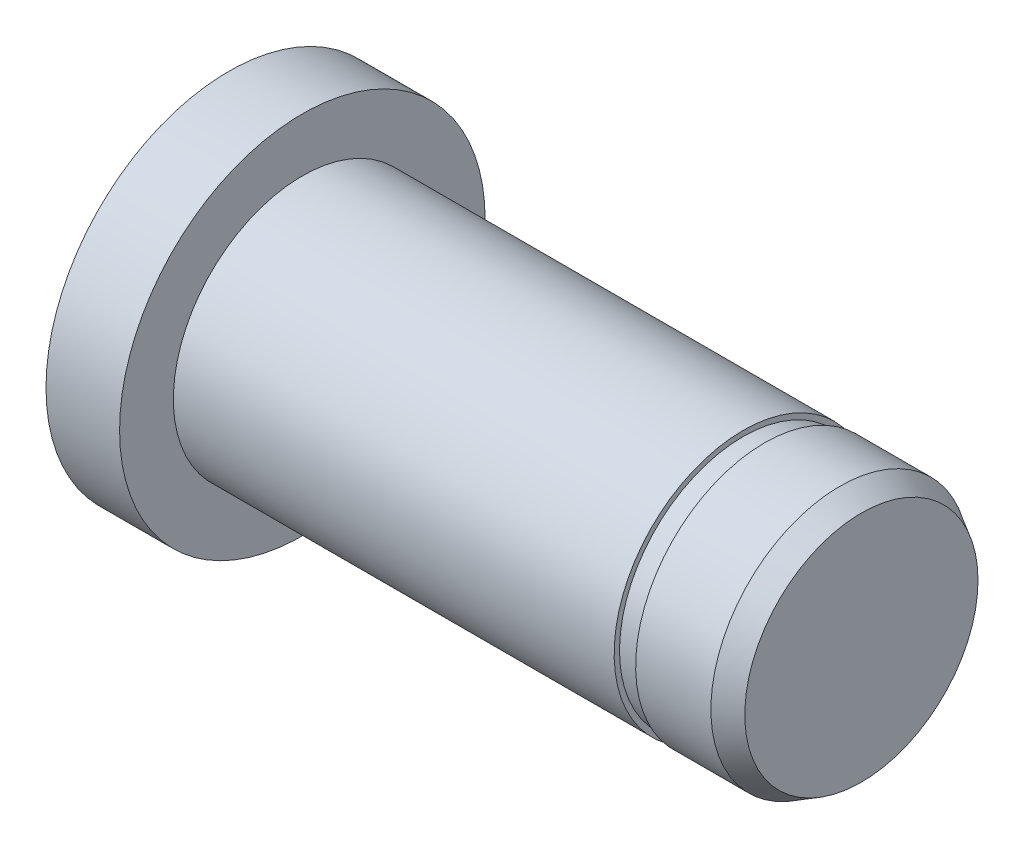
from build123d import *

# Parameters (mm, degrees)
SFAZOWANIE1_SIZE           = 1
SFAZOWANIE1_SIZE2          = 0.577350269
SFAZOWANIE1_PART_2_SIZE    = 1
SFAZOWANIE1_PART_2_SIZE2   = 0.577350269
WYTNIJ_WYCI_GNI_CIE1_START = -4.5
SZKIC2_R                   = 6
SZKIC2_R_2                 = 5.75
WYTNIJ_WYCI_GNI_CIE1_DEPTH = 1


with BuildPart() as part:
    # Szkic1 → Obrót1 (revolve)
    with BuildSketch(Plane.XY):
        Polygon((0, 0), (0, 8.5), (4, 8.5), (4, 6), (30, 6), (30, 0), align=None)
    revolve(axis=Axis((30, 0, 0), (-1, 0, 0)))

    # Sfazowanie1
    sfazowanie1_edges = [part.edges().sort_by_distance(p)[0] for p in [
        (30, -6, 0),
    ]]
    sfazowanie1_side = [part.faces().sort_by_distance(p)[0] for p in [
        (17, -6, 0),
    ]]
    chamfer(sfazowanie1_edges, length=SFAZOWANIE1_SIZE, length2=SFAZOWANIE1_SIZE2, reference=sfazowanie1_side[0])

    # Sfazowanie1 part 2
    sfazowanie1_part_2_edges = [part.edges().sort_by_distance(p)[0] for p in [
        (0, -8.5, 0),
    ]]
    sfazowanie1_part_2_side = [part.faces().sort_by_distance(p)[0] for p in [
        (0, 0, 0),
    ]]
    chamfer(sfazowanie1_part_2_edges, length=SFAZOWANIE1_PART_2_SIZE, length2=SFAZOWANIE1_PART_2_SIZE2, reference=sfazowanie1_part_2_side[0])

    # Szkic2 → Wytnij-wyciągnięcie1 (cut)
    with BuildSketch(Plane(origin=(30, 0, 0), x_dir=(0, 0, -1), z_dir=(1, 0, 0)).offset(WYTNIJ_WYCI_GNI_CIE1_START)):
        Circle(SZKIC2_R)
        Circle(SZKIC2_R_2, mode=Mode.SUBTRACT)
    extrude(amount=-WYTNIJ_WYCI_GNI_CIE1_DEPTH, mode=Mode.SUBTRACT)


solid = part.part
